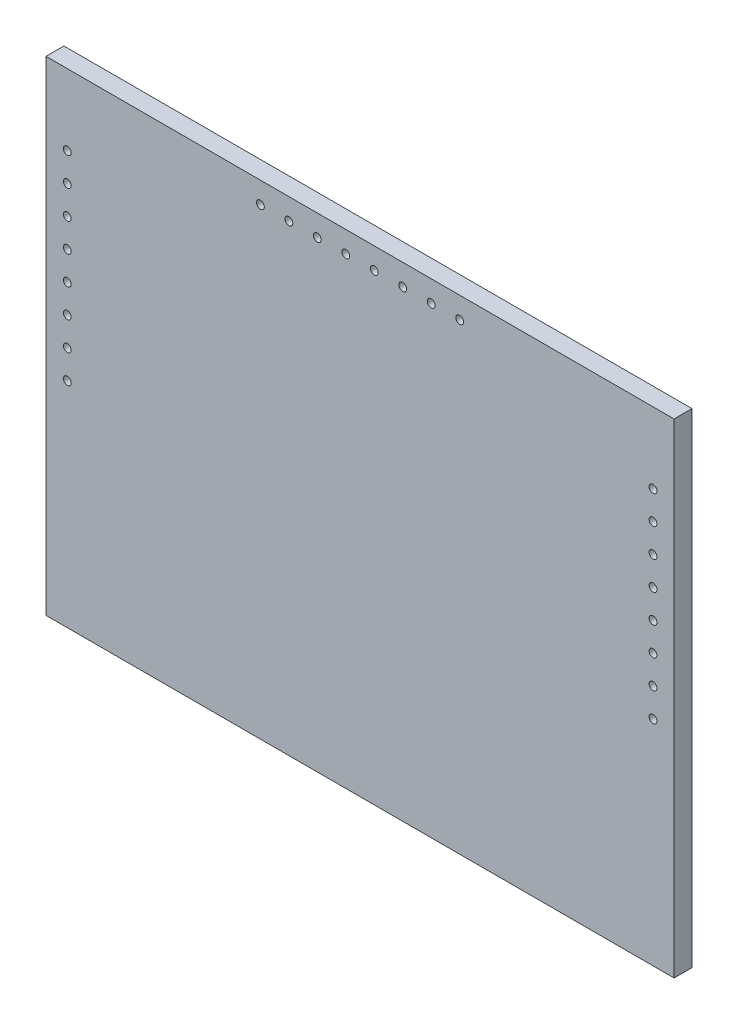
from build123d import *

# Parameters (mm, degrees)
ESBO_O1_W                 = 280.5
ESBO_O1_H                 = 216.23
RESSALTO_EXTRUS_O1_DEPTH  = 8
ESBO_O2_R                 = 1.75
CORTE_EXTRUS_O1_DEPTH     = 100
PADR_O_LINEAR1_COUNT      = 8
PADR_O_LINEAR1_PITCH      = 12.714285714
ESBO_O3_R                 = 1.75
CORTE_EXTRUS_O2_DEPTH     = 10
PADR_O_LINEAR2_COUNT      = 8
PADR_O_LINEAR2_PITCH      = 12.714285714
PADR_O_LINEAR2_COUNT_DIR2 = 2
PADR_O_LINEAR2_PITCH_DIR2 = 261.6


with BuildPart() as part:
    # Esboço1 → Ressalto-extrusão1 (new body)
    with BuildSketch(Plane.XY):
        Rectangle(ESBO_O1_W, ESBO_O1_H)
    extrude(amount=RESSALTO_EXTRUS_O1_DEPTH)

    # Esboço2 → Corte-extrusão1 (cut)
    with BuildSketch(Plane.XY.offset(8)):
        with Locations((44.5, 98.615)):
            Circle(ESBO_O2_R)
    corte_extrus_o1 = extrude(amount=-CORTE_EXTRUS_O1_DEPTH, mode=Mode.SUBTRACT)

    # Padrão linear1: Corte-extrusão1 ×8
    with Locations(*[(-i * PADR_O_LINEAR1_PITCH, 0, 0) for i in range(1, PADR_O_LINEAR1_COUNT)]):
        add(corte_extrus_o1, mode=Mode.SUBTRACT)

    # Esboço3 → Corte-extrusão2 (cut)
    with BuildSketch(Plane(origin=(0, 0, 0), x_dir=(-1, 0, 0), z_dir=(0, 0, -1))):
        with Locations((130.75, 76.385)):
            Circle(ESBO_O3_R)
    corte_extrus_o2 = extrude(amount=-CORTE_EXTRUS_O2_DEPTH, mode=Mode.SUBTRACT)

    # Padrão linear2: Corte-extrus_o2 8 × 2
    with Locations(*[(j * PADR_O_LINEAR2_PITCH_DIR2, -i * PADR_O_LINEAR2_PITCH, 0) for i in range(PADR_O_LINEAR2_COUNT) for j in range(PADR_O_LINEAR2_COUNT_DIR2) if (i, j) != (0, 0)]):
        add(corte_extrus_o2, mode=Mode.SUBTRACT)


solid = part.part
